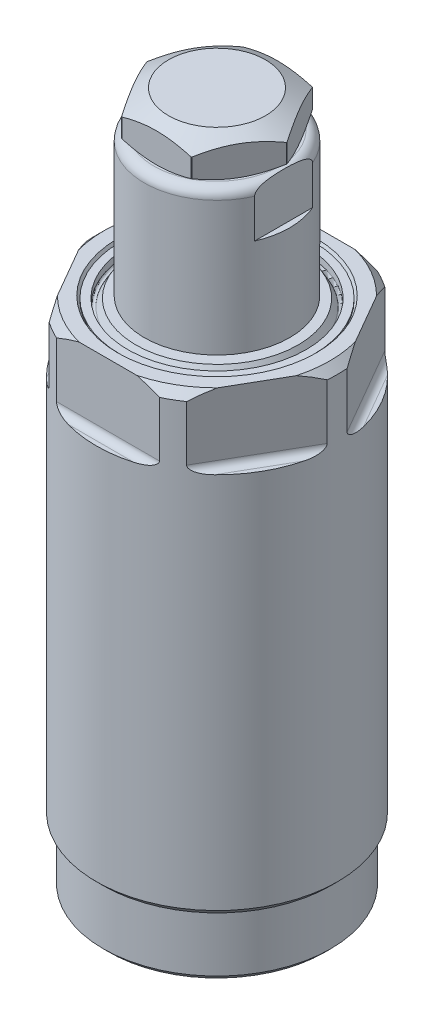
from build123d import *

# Parameters (mm, degrees)
SKETCH2_OUTSIDE_W  = 49.918
SKETCH2_OUTSIDE_H  = 49.918
CUT_EXTRUDE1_DEPTH = 9.144
FILLET1_R          = 0.9144
SKETCH4_W          = 0.79375
SKETCH4_H          = 6.35
CUT_EXTRUDE2_DEPTH = 11.1125
SKETCH5_W          = 4.6736
SKETCH5_H          = 6.35
SKETCH8_OUTSIDE_W  = 54.03
SKETCH8_OUTSIDE_H  = 54.03
CUT_EXTRUDE3_DEPTH = 4.7752


with BuildPart() as part:
    # Sketch1 → Revolve1 (revolve)
    with BuildSketch(Plane.XY):
        with BuildLine():
            Line((9.4615, 0), (10.5918, 0))
            Line((10.5918, 0), (10.9728, 0.381))
            Line((10.9728, 0.381), (14.1097, 0.381))
            Line((14.1097, 0.381), (14.8717, 1.143))
            Line((14.8717, 1.143), (14.8717, 8.3058))
            Line((14.8717, 8.3058), (15.7988, 9.2329))
            Line((15.7988, 9.2329), (15.7988, 66.802))
            Line((15.7988, 66.802), (14.7828, 67.818))
            Line((14.7828, 67.818), (12.993293937, 67.818))
            Line((12.993293937, 67.818), (12.7, 67.31))
            Line((12.7, 67.31), (12.7, 67.5386))
            Line((12.7, 67.5386), (11.684, 67.5386))
            Line((11.684, 67.5386), (11.684, 66.6496))
            ThreePointArc((11.684, 66.6496), (11.495740037, 66.40425484), (11.210029547, 66.5226))
            Line((11.210029547, 66.5226), (10.623441674, 67.5386))
            Line((10.623441674, 67.5386), (0, 67.5386))
            Line((0, 67.5386), (0, 5.1308))
            Line((0, 5.1308), (2.3876, 5.1308))
            Line((2.3876, 5.1308), (2.3876, 1.3208))
            Line((2.3876, 1.3208), (8.5725, 1.3208))
            ThreePointArc((8.5725, 1.3208), (7.943882072, -0.196817928), (9.4615, 0.4318))
            Line((9.4615, 0.4318), (9.4615, 0))
        make_face()
    revolve(axis=Axis((0, 0, 0), (0, 1, 0)))

    # Sketch2 outside → Cut-Extrude1 (cut)
    with BuildSketch(Plane(origin=(0, 67.818, 0), x_dir=(1, 0, 0), z_dir=(0, 1, 0))):
        Rectangle(SKETCH2_OUTSIDE_W, SKETCH2_OUTSIDE_H)
        Polygon((16.497783942, 0), (8.248891971, 14.2875), (-8.248891971, 14.2875), (-16.497783942, 0), (-8.248891971, -14.2875), (8.248891971, -14.2875), align=None, mode=Mode.SUBTRACT)
    extrude(amount=-CUT_EXTRUDE1_DEPTH, mode=Mode.SUBTRACT)

    # Fillet1
    fillet1_edges = [part.edges().sort_by_distance(p)[0] for p in [
        (-12.373337957, 58.674, -7.14375),
        (0, 58.674, -14.2875),
        (12.373337957, 58.674, -7.14375),
        (12.373337957, 58.674, 7.14375),
        (0, 58.674, 14.2875),
        (-12.373337957, 58.674, 7.14375),
    ]]
    fillet(fillet1_edges, radius=FILLET1_R)


with BuildPart() as body_2:
    # Sketch3 → Revolve2 (revolve)
    with BuildSketch(Plane.XY):
        with BuildLine():
            Line((0, 67.818), (0, 86.6394))
            Line((0, 86.6394), (8.255, 86.6394))
            ThreePointArc((8.255, 86.6394), (9.153025612, 86.267425612), (9.525, 85.3694))
            Line((9.525, 85.3694), (9.525, 67.818))
            Line((9.525, 67.818), (0, 67.818))
        make_face()
    revolve(axis=Axis((0, 43.688, 0), (0, 1, 0)))

    # Sketch4 → Cut-Extrude2 (cut, symmetric)
    with BuildSketch(Plane.XY):
        with Locations((-9.128125, 83.4644)):
            Rectangle(SKETCH4_W, SKETCH4_H)
        with Locations((9.128125, 83.4644)):
            Rectangle(SKETCH4_W, SKETCH4_H)
    extrude(amount=CUT_EXTRUDE2_DEPTH, both=True, mode=Mode.SUBTRACT)

    # Sketch5 → 7_16-14 Tapped Hole1 (revolve, cut)
    with BuildSketch(Plane(origin=(0, 86.6394, 0), x_dir=(0, 0, 1), z_dir=(1, 0, 0))):
        with Locations((2.3368, 3.175)):
            Rectangle(SKETCH5_W, SKETCH5_H)
    revolve(axis=Axis((0, 92.9894, 0), (0, -1, 0)), mode=Mode.SUBTRACT)

    # Sketch7 → Revolve3 (revolve)
    with BuildSketch(Plane.XY):
        Polygon((0, 91.4146), (6.35, 91.4146), (9.144, 89.801483348), (9.144, 87.3359731), (7.9375, 86.6394), (0, 86.6394), align=None)
    revolve(axis=Axis((0, 0, 0), (0, -1, 0)))

    # Sketch8 outside → Cut-Extrude3 (cut)
    with BuildSketch(Plane(origin=(0, 91.4146, 0), x_dir=(1, 0, 0), z_dir=(0, 1, 0))):
        Rectangle(SKETCH8_OUTSIDE_W, SKETCH8_OUTSIDE_H)
        Polygon((9.165435523, 0), (4.582717762, 7.9375), (-4.582717762, 7.9375), (-9.165435523, 0), (-4.582717762, -7.9375), (4.582717762, -7.9375), align=None, mode=Mode.SUBTRACT)
    extrude(amount=-CUT_EXTRUDE3_DEPTH, mode=Mode.SUBTRACT)


solid = Compound([part.part, body_2.part])
